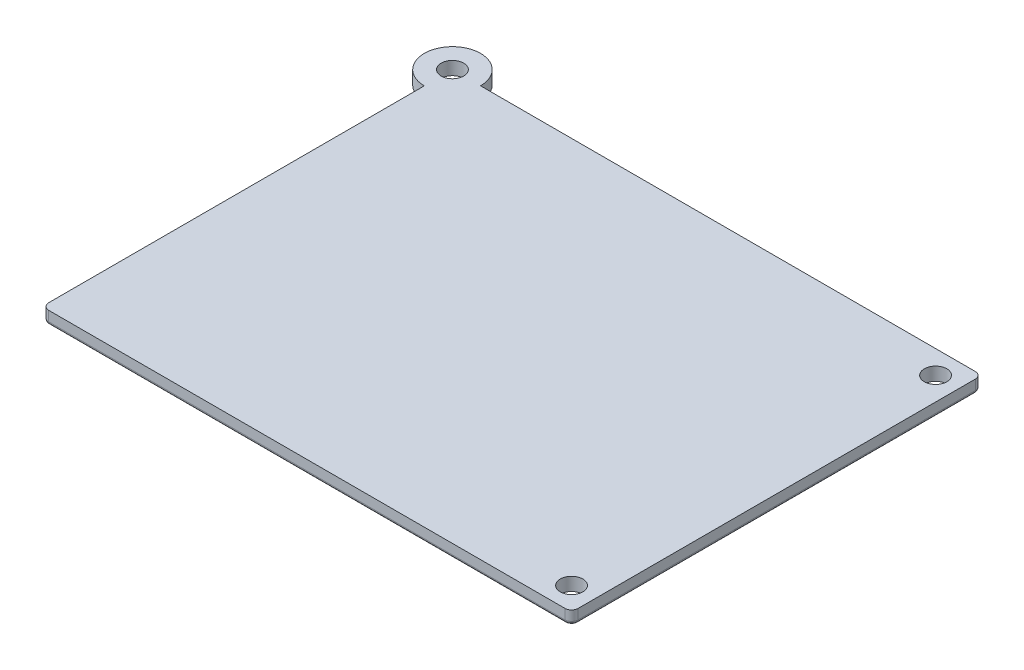
from build123d import *

# Parameters (mm, degrees)
MAIN_BODY_DEPTH                          = 2
CORNERS_R                                = 1
EDGE_2_R                                 = 0.5
LID_START                                = -2
SKETCH7_R                                = 1.7
LID_HOLES_DEPTH                          = 2
SKETCH4_R                                = 2.325
BOSS_EXTRUDE3_DEPTH                      = 1.6
FILLET3_R                                = 0.05
LPATTERN5_COUNT                          = 4
LPATTERN5_PITCH                          = 8
FILLET3_OF_LPATTERN5_R                   = 0.05
SKETCH9_R                                = 2.325
LEGO_PEGS_DEPTH                          = 1.6
SOFTEN_3D_PRINTED_CORNERS_R              = 0.05
LPATTERN6_COUNT                          = 4
LPATTERN6_PITCH                          = 8
SOFTEN_3D_PRINTED_CORNERS_OF_LPATTERN6_R = 0.05


with BuildPart() as part:
    # Sketch1 → Main Body (new body)
    with BuildSketch(Plane(origin=(0, 0, 0), x_dir=(1, 0, 0), z_dir=(0, 1, 0))):
        with BuildLine():
            Line((-40, -31), (40, -31))
            Line((40, -31), (40, 31))
            Line((40, 31), (-35.75, 31))
            ThreePointArc((-35.75, 31), (-43.00520382, 34.00520382), (-40, 26.75))
            Line((-40, 26.75), (-40, -31))
        make_face()
    extrude(amount=MAIN_BODY_DEPTH)

    # Corners
    corners_edges = [part.edges().sort_by_distance(p)[0] for p in [
        (40, 1, 31),
        (-40, 1, 31),
        (40, 1, -31),
    ]]
    fillet(corners_edges, radius=CORNERS_R)

    # Edge 2
    edge_2_edges = [part.edges().sort_by_distance(p)[0] for p in [
        (0, 0, 31),
        (40, 0, 0),
        (1.625, 0, -31),
        (39.707106781, 0, 30.707106781),
        (39.707106781, 0, -30.707106781),
        (-39.707106781, 0, 30.707106781),
        (-40, 0, 1.625),
    ]]
    fillet(edge_2_edges, radius=EDGE_2_R)

    # Sketch7 → Lid Holes (cut)
    with BuildSketch(Plane(origin=(0, 0, 0), x_dir=(-1, 0, 0), z_dir=(0, -1, 0)).offset(LID_START)):
        with Locations((40, 31)):
            Circle(SKETCH7_R)
        with Locations((-36.5, -27.5)):
            Circle(SKETCH7_R)
        with Locations((-36.5, 27.5)):
            Circle(SKETCH7_R)
    extrude(amount=LID_HOLES_DEPTH, mode=Mode.SUBTRACT)

    # Sketch4 → Boss-Extrude3 (add)
    with BuildSketch(Plane(origin=(0, 0, 0), x_dir=(-1, 0, 0), z_dir=(0, -1, 0))):
        with Locations((-30, 24)):
            Circle(SKETCH4_R)
        with Locations((-30, 16)):
            Circle(SKETCH4_R)
    boss_extrude3 = extrude(amount=BOSS_EXTRUDE3_DEPTH)

    # Fillet3
    fillet3_edges = [part.edges().sort_by_distance(p)[0] for p in [
        (32.325, -1.6, -24),
    ]]
    fillet(fillet3_edges, radius=FILLET3_R)

    # LPattern5: Boss-Extrude3 ×4
    with Locations(*[(-i * LPATTERN5_PITCH, 0, 0) for i in range(1, LPATTERN5_COUNT)]):
        add(boss_extrude3)

    # Fillet3 of LPattern5
    fillet3_of_lpattern5_edges = [part.edges().sort_by_distance(p)[0] for p in [
        (24.325, -1.6, -24),
        (16.325, -1.6, -24),
        (8.325, -1.6, -24),
    ]]
    fillet(fillet3_of_lpattern5_edges, radius=FILLET3_OF_LPATTERN5_R)

    # Sketch9 → LEGO Pegs (add)
    with BuildSketch(Plane.XZ):
        with Locations((30.911091031, 16.256726588)):
            Circle(SKETCH9_R)
        with Locations((25.088908969, 21.743273412)):
            Circle(SKETCH9_R)
    lego_pegs = extrude(amount=LEGO_PEGS_DEPTH)

    # Soften 3D printed corners
    soften_3d_printed_corners_edges = [part.edges().sort_by_distance(p)[0] for p in [
        (28.586091031, -1.6, 16.256726588),
        (22.763908969, -1.6, 21.743273412),
    ]]
    fillet(soften_3d_printed_corners_edges, radius=SOFTEN_3D_PRINTED_CORNERS_R)

    # LPattern6: LEGO Pegs ×4
    with Locations(*[Vector(-0.685818353, 0, -0.727772758) * (i * LPATTERN6_PITCH) for i in range(1, LPATTERN6_COUNT)]):
        add(lego_pegs)

    # Soften 3D printed corners of LPattern6
    soften_3d_printed_corners_of_lpattern6_edges = [part.edges().sort_by_distance(p)[0] for p in [
        (23.099544207, -1.6, 10.434544527),
        (17.277362146, -1.6, 15.92109135),
        (17.612997384, -1.6, 4.612362466),
        (11.790815323, -1.6, 10.098909289),
        (12.12645056, -1.6, -1.209819595),
        (6.304268499, -1.6, 4.276727228),
    ]]
    fillet(soften_3d_printed_corners_of_lpattern6_edges, radius=SOFTEN_3D_PRINTED_CORNERS_OF_LPATTERN6_R)


solid = part.part
